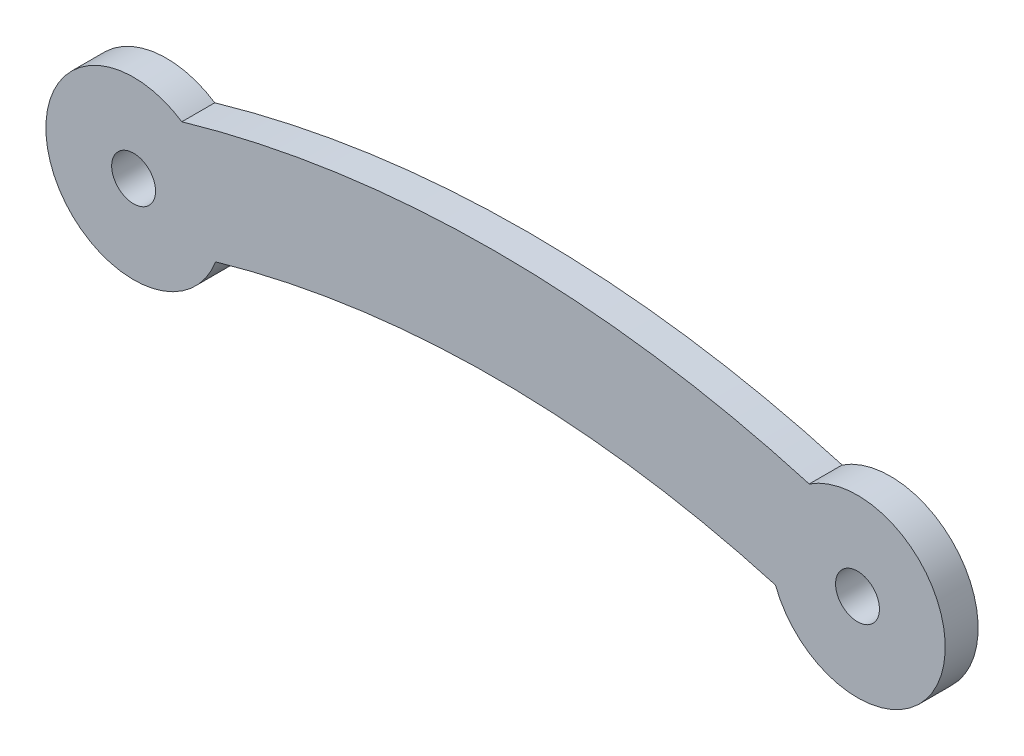
from build123d import *

# Parameters (mm, degrees)
SKETCH1_R           = 1
BOSS_EXTRUDE1_DEPTH = 1.5


with BuildPart() as part:
    # Sketch1 → Boss-Extrude1 (new body)
    with BuildSketch(Plane.XY):
        with BuildLine():
            ThreePointArc((2.199923484, 3.340709006), (-3.805763528, -1.231326103), (3.739869974, -1.418933606))
            ThreePointArc((3.739869974, -1.418933606), (16.5, 0.374164402), (29.260130026, -1.418933606))
            ThreePointArc((29.260130026, -1.418933606), (36.805763528, -1.231326103), (30.800076516, 3.340709006))
            ThreePointArc((30.800076516, 3.340709006), (16.5, 5.374164402), (2.199923484, 3.340709006))
        make_face()
        Circle(SKETCH1_R, mode=Mode.SUBTRACT)
        with Locations((33, 0)):
            Circle(SKETCH1_R, mode=Mode.SUBTRACT)
    extrude(amount=BOSS_EXTRUDE1_DEPTH)


solid = part.part
